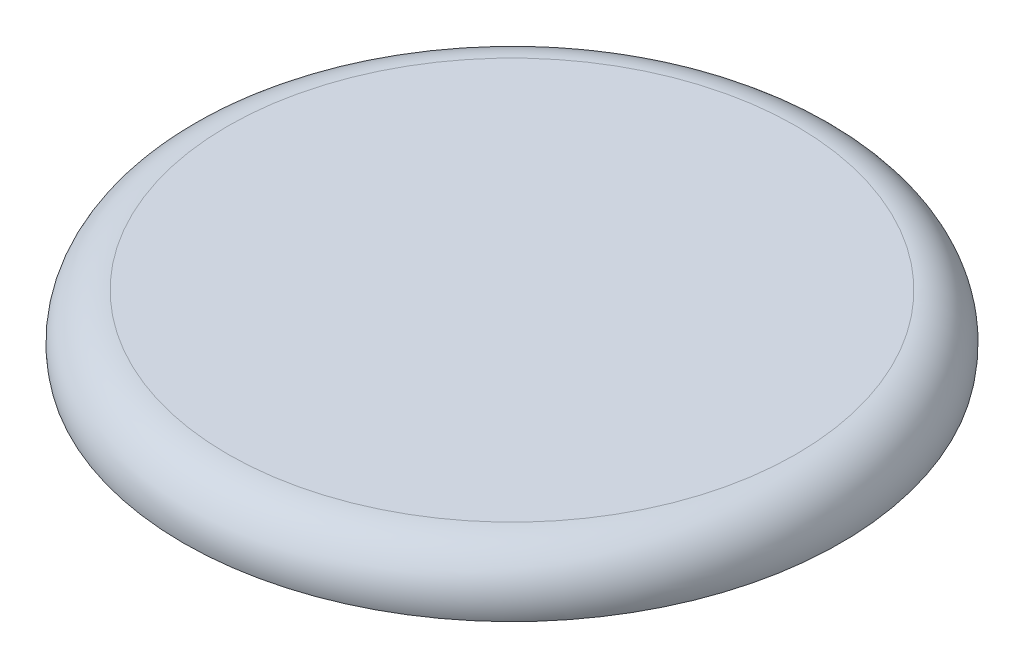
from build123d import *

# Parameters (mm, degrees)
SKETCH1_R           = 75
BOSS_EXTRUDE1_DEPTH = 100
BOSS_EXTRUDE1_TAPER = 12
SKETCH3_R           = 70
CUT_EXTRUDE1_DEPTH  = 80
CUT_EXTRUDE1_TAPER  = 12
FILLET1_R           = 10
SKETCH4_R           = 15
CUT_EXTRUDE2_DEPTH  = 90
SKETCH5_R           = 14.5
SKETCH5_R_2         = 12.5
BOSS_EXTRUDE2_DEPTH = 30
SKETCH6_R           = 12.5
CUT_EXTRUDE3_DEPTH  = 30
SKETCH7_R           = 73.5
CUT_EXTRUDE4_DEPTH  = 130


with BuildPart() as part:
    # Sketch1 → Boss-Extrude1 (new body)
    with BuildSketch(Plane(origin=(0, 0, 0), x_dir=(1, 0, 0), z_dir=(0, 1, 0))):
        Circle(SKETCH1_R)
    extrude(amount=-BOSS_EXTRUDE1_DEPTH, taper=BOSS_EXTRUDE1_TAPER)

    # Sketch3 → Cut-Extrude1 (cut)
    with BuildSketch(Plane(origin=(0, -10, 0), x_dir=(1, 0, 0), z_dir=(0, 1, 0))):
        Circle(SKETCH3_R)
    extrude(amount=-CUT_EXTRUDE1_DEPTH, taper=CUT_EXTRUDE1_TAPER, mode=Mode.SUBTRACT)

    # Fillet1
    fillet1_edges = [part.edges().sort_by_distance(p)[0] for p in [
        (-75, 0, 0),
    ]]
    fillet(fillet1_edges, radius=FILLET1_R)

    # Sketch4 → Cut-Extrude2 (cut)
    with BuildSketch(Plane.XY):
        with Locations((-25, -40)):
            Circle(SKETCH4_R)
        with Locations((25, -40)):
            Circle(SKETCH4_R)
        with BuildLine():
            Line((-15, -70), (15, -70))
            ThreePointArc((15, -70), (0, -85), (-15, -70))
        make_face()
    extrude(amount=-CUT_EXTRUDE2_DEPTH, mode=Mode.SUBTRACT)

    # Sketch5 → Boss-Extrude2 (add)
    with BuildSketch(Plane.XZ.offset(100)):
        Circle(SKETCH5_R)
        Circle(SKETCH5_R_2, mode=Mode.SUBTRACT)
    extrude(amount=BOSS_EXTRUDE2_DEPTH)

    # Sketch6 → Cut-Extrude3 (cut)
    with BuildSketch(Plane.XZ.offset(100)):
        Circle(SKETCH6_R)
    extrude(amount=-CUT_EXTRUDE3_DEPTH, mode=Mode.SUBTRACT)

    # Sketch7 → Cut-Extrude4 (cut)
    with BuildSketch(Plane(origin=(0, -12.079116908, 0), x_dir=(1, 0, 0), z_dir=(0, 1, 0))):
        Circle(SKETCH7_R)
    extrude(amount=-CUT_EXTRUDE4_DEPTH, mode=Mode.SUBTRACT)


solid = part.part
